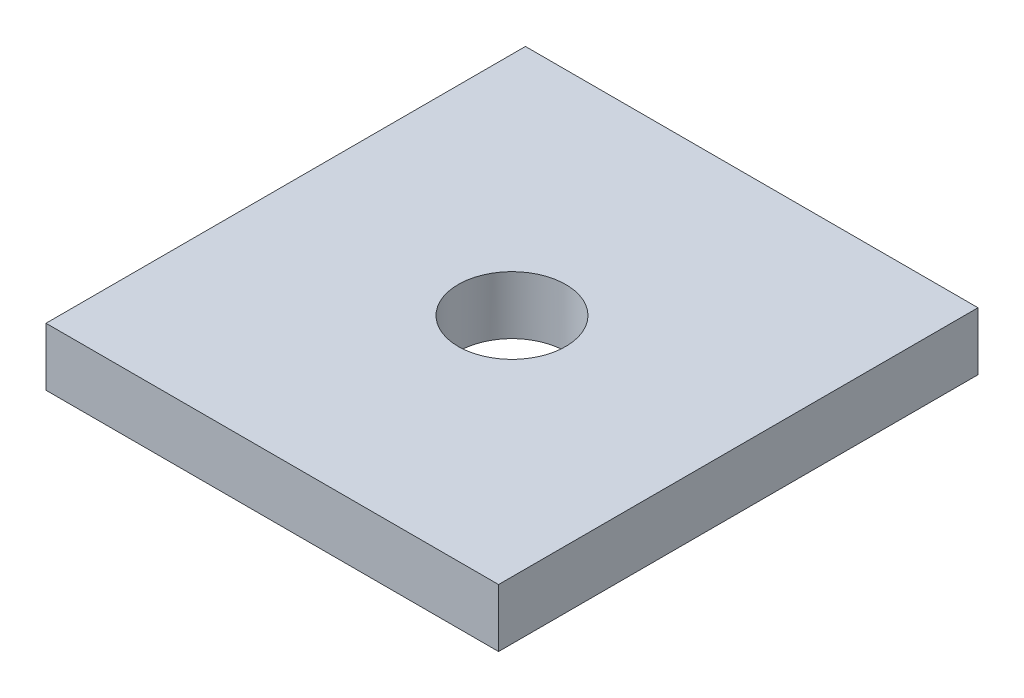
from build123d import *

# Parameters (mm, degrees)
SKETCH1_W           = 53.467
SKETCH1_H           = 56.642
BOSS_EXTRUDE2_DEPTH = 6.858
SKETCH2_R           = 6.35
CUT_EXTRUDE1_DEPTH  = 25.4


with BuildPart() as part:
    # Sketch1 → Boss-Extrude2 (new body)
    with BuildSketch(Plane(origin=(0, 0, 0), x_dir=(1, 0, 0), z_dir=(0, 1, 0))):
        Rectangle(SKETCH1_W, SKETCH1_H)
    extrude(amount=BOSS_EXTRUDE2_DEPTH)

    # Sketch2 → Cut-Extrude1 (cut)
    with BuildSketch(Plane(origin=(0, 6.858, 0), x_dir=(1, 0, 0), z_dir=(0, 1, 0))):
        Circle(SKETCH2_R)
    extrude(amount=-CUT_EXTRUDE1_DEPTH, mode=Mode.SUBTRACT)


solid = part.part
